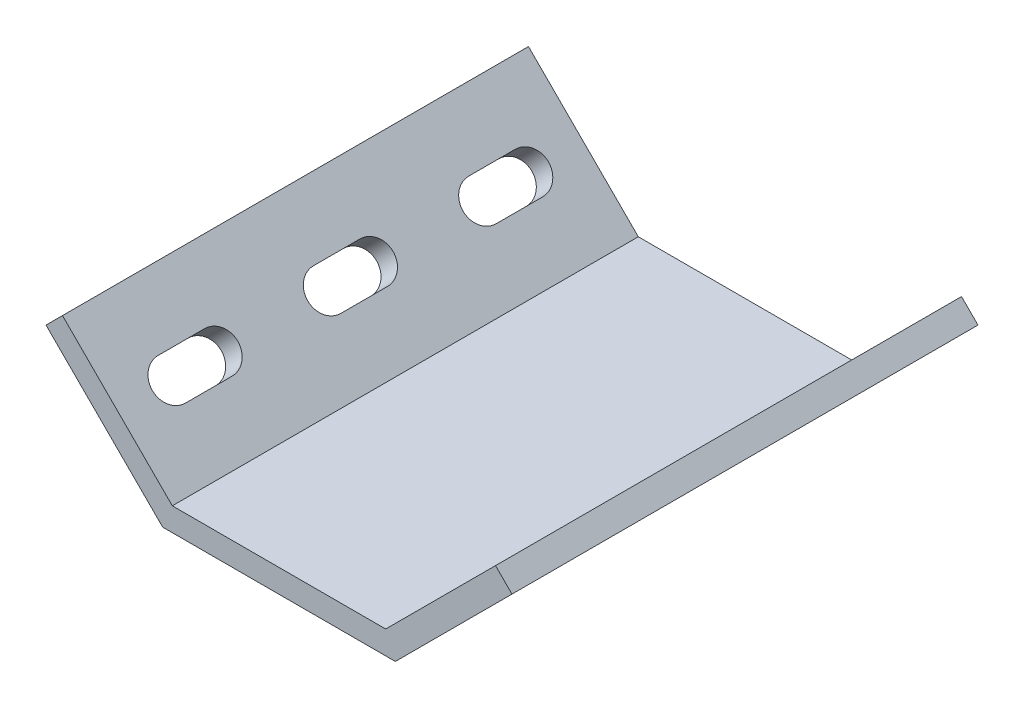
from build123d import *

# Parameters (mm, degrees)
EXTRUDE_1_DEPTH        = 20
CUT_EXTRUDE_1_DEPTH    = 14.621320344
PATTERN_LINEAR_1_COUNT = 3
PATTERN_LINEAR_1_PITCH = 20


with BuildPart() as part:
    # Эскиз1 → Вытянуть-Тонкостенный1 (new body)
    with BuildSketch(Plane.XY):
        Polygon((-27.878679656, 14.142135624), (-13.736544033, 0), (13.736544033, 0), (27.878679656, 14.142135624), (30, 12.02081528), (14.97918472, -3), (-14.97918472, -3), (-30, 12.02081528), align=None)
    extrude(amount=EXTRUDE_1_DEPTH)

    # Эскиз2 → Вырез-Вытянуть1 (cut, through all)
    with BuildSketch(Plane(origin=(-6.868272016, -6.868272016, 0), x_dir=(0, 0, -1), z_dir=(0.707106781, 0.707106781, 0))):
        with BuildLine():
            Line((-7, 17.213203436), (-13, 17.213203436))
            ThreePointArc((-13, 17.213203436), (-15.5, 19.713203436), (-13, 22.213203436))
            Line((-13, 22.213203436), (-7, 22.213203436))
            ThreePointArc((-7, 22.213203436), (-4.5, 19.713203436), (-7, 17.213203436))
        make_face()
    cut_extrude_1 = extrude(amount=-CUT_EXTRUDE_1_DEPTH, mode=Mode.SUBTRACT)

    # Зеркальное отражение1: Вырез-Вытянуть1 across plane
    add(cut_extrude_1.mirror(Plane(origin=(0, 0, 0), x_dir=(0, 0, 1), z_dir=(1, 0, 0))), mode=Mode.SUBTRACT)


with BuildPart() as pattern_linear_1_1:
    # Линейный массив1: pattern copy
    add(part.part.moved(Location(Vector(0, 0, -1) * (1 * PATTERN_LINEAR_1_PITCH))))


with BuildPart() as pattern_linear_1_2:
    # Линейный массив1: pattern copy
    add(part.part.moved(Location(Vector(0, 0, -1) * (2 * PATTERN_LINEAR_1_PITCH))))


with BuildPart() as part_1:
    add(part.part)

    # Combine 2: union Линейный массив1_1, Линейный массив1_2
    add(pattern_linear_1_1.part)
    add(pattern_linear_1_2.part)


solid = part_1.part
